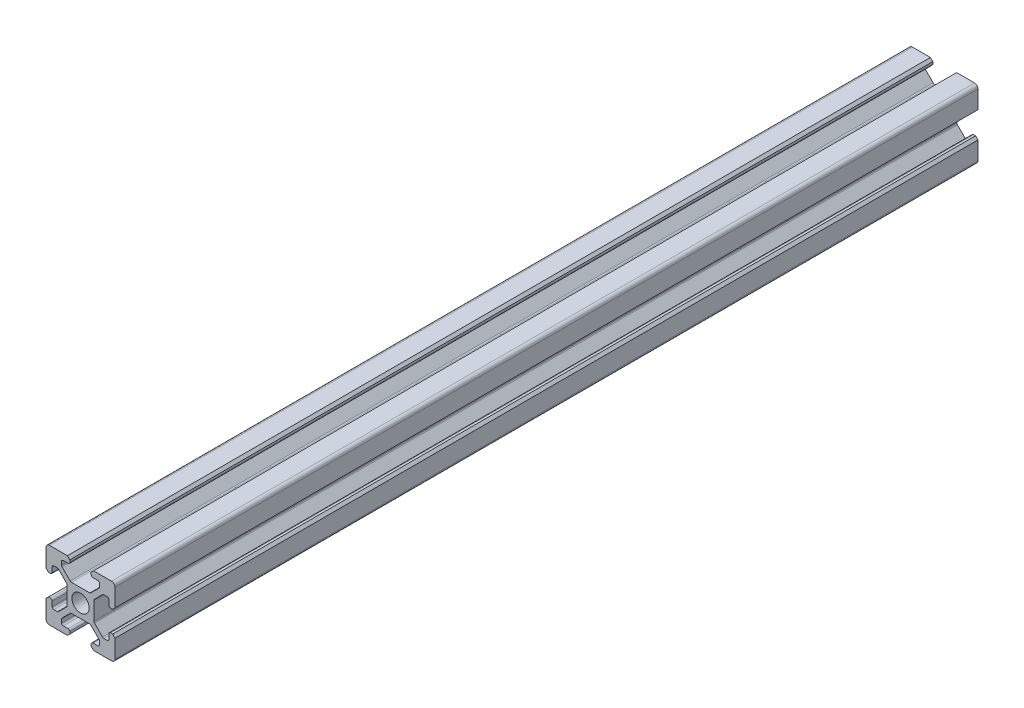
from build123d import *

# Parameters (mm, degrees)
SKETCH1_R           = 2.5
BOSS_EXTRUDE1_DEPTH = 125
FILLET1_R           = 0.5
FILLET2_R           = 0.5
FILLET3_R           = 1
SKETCH2_R           = 1.6
CUT_EXTRUDE1_DEPTH  = 14.9


with BuildPart() as part:
    # Sketch1 → Boss-Extrude1 (new body, symmetric)
    with BuildSketch(Plane.XY):
        Polygon((3.9, -2.839339828), (6.560660172, -5.5), (8.200660172, -5.5), (8.200660172, -3.1), (9.3, -3.1), (10, -3.8), (10, -10), (3.8, -10), (3.1, -9.3), (3.1, -8.200660172), (5.5, -8.200660172), (5.5, -6.560660172), (2.839339828, -3.9), (-2.839339828, -3.9), (-5.5, -6.560660172), (-5.5, -8.200660172), (-3.1, -8.200660172), (-3.1, -9.3), (-3.8, -10), (-10, -10), (-10, -3.8), (-9.3, -3.1), (-8.200660172, -3.1), (-8.200660172, -5.5), (-6.560660172, -5.5), (-3.9, -2.839339828), (-3.9, 2.839339828), (-6.560660172, 5.5), (-8.200660172, 5.5), (-8.200660172, 3.1), (-9.3, 3.1), (-10, 3.8), (-10, 10), (-3.8, 10), (-3.1, 9.3), (-3.1, 8.200660172), (-5.5, 8.200660172), (-5.5, 6.560660172), (-2.839339828, 3.9), (2.839339828, 3.9), (5.5, 6.560660172), (5.5, 8.200660172), (3.1, 8.200660172), (3.1, 9.3), (3.8, 10), (10, 10), (10, 3.8), (9.3, 3.1), (8.200660172, 3.1), (8.200660172, 5.5), (6.560660172, 5.5), (3.9, 2.839339828), align=None)
        Circle(SKETCH1_R, mode=Mode.SUBTRACT)
    extrude(amount=BOSS_EXTRUDE1_DEPTH, both=True)

    # Fillet1
    fillet1_edges = [part.edges().sort_by_distance(p)[0] for p in [
        (-2.839339828, 3.9, 0),
        (2.839339828, 3.9, 0),
        (3.9, 2.839339828, 0),
        (3.9, -2.839339828, 0),
        (2.839339828, -3.9, 0),
        (-2.839339828, -3.9, 0),
        (-3.9, -2.839339828, 0),
        (-3.9, 2.839339828, 0),
    ]]
    fillet(fillet1_edges, radius=FILLET1_R)

    # Fillet2
    fillet2_edges = [part.edges().sort_by_distance(p)[0] for p in [
        (-5.5, 6.560660172, 0),
        (5.5, 6.560660172, 0),
        (5.5, 8.200660172, 0),
        (3.1, 8.200660172, 0),
        (8.200660172, 3.1, 0),
        (8.200660172, 5.5, 0),
        (6.560660172, 5.5, 0),
        (6.560660172, -5.5, 0),
        (8.200660172, -5.5, 0),
        (8.200660172, -3.1, 0),
        (3.1, -8.200660172, 0),
        (5.5, -8.200660172, 0),
        (5.5, -6.560660172, 0),
        (-5.5, -6.560660172, 0),
        (-5.5, -8.200660172, 0),
        (-3.1, -8.200660172, 0),
        (-8.200660172, -3.1, 0),
        (-8.200660172, -5.5, 0),
        (-6.560660172, -5.5, 0),
        (-6.560660172, 5.5, 0),
        (-8.200660172, 5.5, 0),
        (-8.200660172, 3.1, 0),
        (-3.1, 8.200660172, 0),
        (-5.5, 8.200660172, 0),
    ]]
    fillet(fillet2_edges, radius=FILLET2_R)

    # Fillet3
    fillet3_edges = [part.edges().sort_by_distance(p)[0] for p in [
        (10, 10, 0),
        (10, -10, 0),
        (-10, -10, 0),
        (-10, 10, 0),
    ]]
    fillet(fillet3_edges, radius=FILLET3_R)

    # Sketch2 → Cut-Extrude1 (cut, through all)
    with BuildSketch(Plane(origin=(0, 3.9, 0), x_dir=(1, 0, 0), z_dir=(0, 1, 0))):
        with Locations((0, 117.4)):
            Circle(SKETCH2_R)
    extrude(amount=-CUT_EXTRUDE1_DEPTH, mode=Mode.SUBTRACT)


solid = part.part
